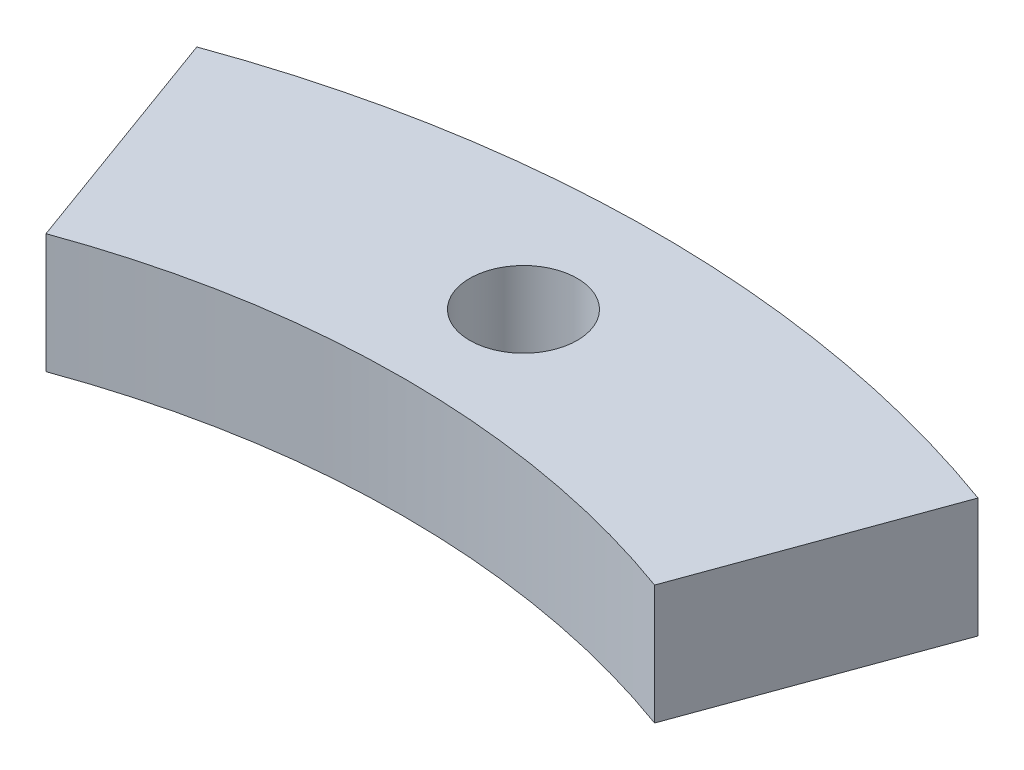
from build123d import *

# Parameters (mm, degrees)
SKETCH1_R               = 43
SKETCH1_R_2             = 33.5
BOSS_EXTRUDE1_DEPTH     = 4.5
CUT_EXTRUDE1_START      = -5.5
CUT_EXTRUDE1_DEPTH      = 6.5
SKETCH3_R               = 2.025
CUT_EXTRUDE2_DEPTH      = 1
CUT_EXTRUDE2_DEPTH_BACK = 5.5


with BuildPart() as part:
    # Sketch1 → Boss-Extrude1 (new body)
    with BuildSketch(Plane(origin=(0, 0, 0), x_dir=(1, 0, 0), z_dir=(0, 1, 0))):
        Circle(SKETCH1_R)
        Circle(SKETCH1_R_2, mode=Mode.SUBTRACT)
    extrude(amount=BOSS_EXTRUDE1_DEPTH)

    # Sketch2 → Cut-Extrude1 (cut)
    with BuildSketch(Plane(origin=(0, 4.5, 0), x_dir=(1, 0, 0), z_dir=(0, 1, 0)).offset(CUT_EXTRUDE1_START)):
        with BuildLine():
            Line((0, 0), (0, -52.31984462))
            ThreePointArc((0, -52.31984462), (51.524988618, -9.085245674), (17.894440756, 49.16457191))
            Line((17.894440756, 49.16457191), (0, 0))
        make_face()
    cut_extrude1 = extrude(amount=CUT_EXTRUDE1_DEPTH, mode=Mode.SUBTRACT)

    # Mirror1: Cut-Extrude1 across plane
    add(cut_extrude1.mirror(Plane(origin=(0, 0, 0), x_dir=(0, 0, 1), z_dir=(1, 0, 0))), mode=Mode.SUBTRACT)

    # Sketch3 → Cut-Extrude2 (cut, two sides)
    with BuildSketch(Plane(origin=(0, 4.5, 0), x_dir=(1, 0, 0), z_dir=(0, 1, 0))) as cut_extrude2_sk:
        with Locations((0, 38)):
            Circle(SKETCH3_R)
    extrude(amount=CUT_EXTRUDE2_DEPTH, mode=Mode.SUBTRACT)
    extrude(cut_extrude2_sk.sketch, amount=-CUT_EXTRUDE2_DEPTH_BACK, mode=Mode.SUBTRACT)


solid = part.part
